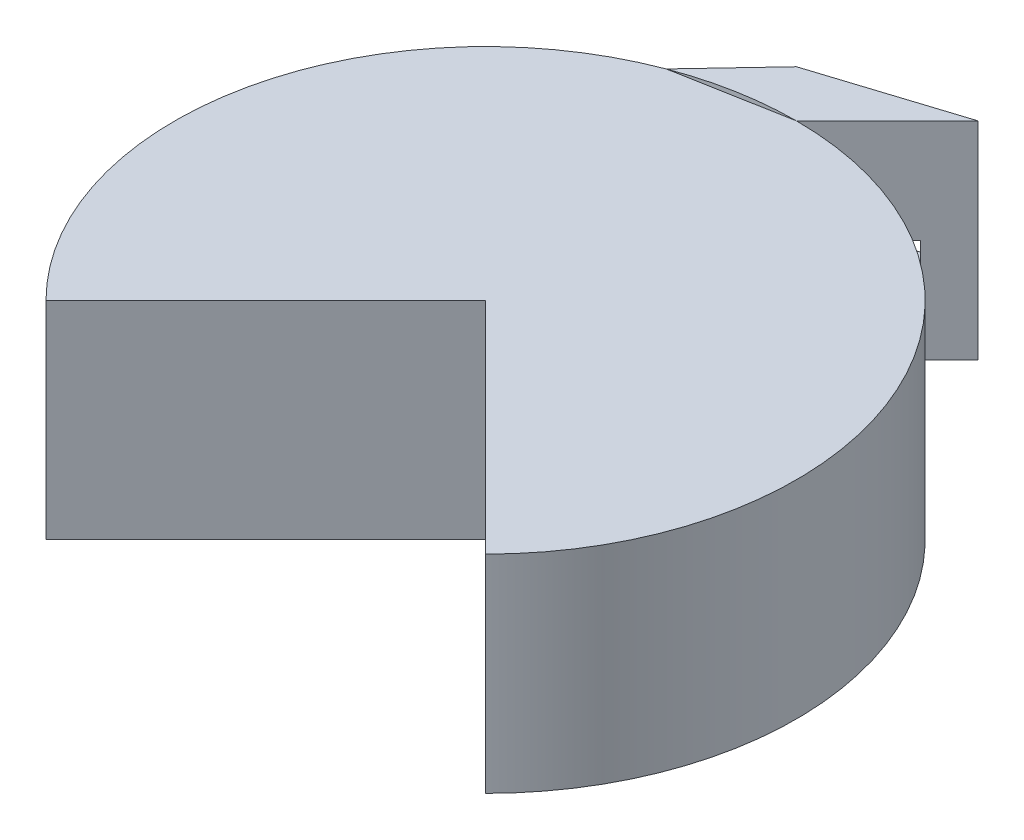
from build123d import *

# Parameters (mm, degrees)
BOSS_EXTRUDE2_DEPTH = 50
CUT_EXTRUDE1_DEPTH  = 16
SKETCH3_R           = 18
CUT_EXTRUDE2_DEPTH  = 30
SKETCH4_R           = 18
CUT_EXTRUDE3_DEPTH  = 30
SKETCH7_R           = 15
CUT_EXTRUDE4_DEPTH  = 30
SKETCH9_R           = 15
CUT_EXTRUDE5_DEPTH  = 30


with BuildPart() as part:
    # Sketch1 → Boss-Extrude2 (new body)
    with BuildSketch(Plane(origin=(0, 0, 0), x_dir=(1, 0, 0), z_dir=(0, 1, 0))):
        with BuildLine():
            Line((0, 75), (0, 0))
            Line((0, 0), (53.033008589, -53.033008589))
            ThreePointArc((53.033008589, -53.033008589), (69.290964938, -28.701257427), (75, 0))
            ThreePointArc((75, 0), (53.033008589, 53.033008589), (0, 75))
        make_face()
        with BuildLine():
            Line((-53.033008589, -53.033008589), (0, 0))
            Line((0, 0), (0, 75))
            Line((0, 75), (-75, 0))
            ThreePointArc((-75, 0), (-69.290964938, -28.701257427), (-53.033008589, -53.033008589))
        make_face()
        with BuildLine():
            Line((-75, 0), (0, 75))
            Line((0, 75), (-26.555455015, 70.141341654))
            ThreePointArc((-26.555455015, 70.141341654), (-61.711664724, 42.622417071), (-75, 0))
        make_face()
        with BuildLine():
            ThreePointArc((-26.555455015, 70.141341654), (-13.498136464, 73.775336746), (0, 75))
            Line((0, 75), (-11.313708499, 86.313708499))
            Line((-11.313708499, 86.313708499), (-26.555455015, 70.141341654))
        make_face()
        Polygon((0, 75), (21.906905273, 96.906905273), (-11.313708499, 86.313708499), align=None)
    extrude(amount=BOSS_EXTRUDE2_DEPTH)

    # Sketch2 → Cut-Extrude1 (cut)
    with BuildSketch(Plane(origin=(-26.027142022, 0, -81.621974096), x_dir=(-0.952734996, 0, 0.303802613), z_dir=(-0.303802613, 0, -0.952734996))):
        Polygon((-32.87770529, 25), (-41.594875837, 25), (-41.594875837, 19), (-21.594875837, 19), (-21.594875837, 25), align=None)
    extrude(amount=-CUT_EXTRUDE1_DEPTH, mode=Mode.SUBTRACT)

    # Sketch3 → Cut-Extrude2 (cut)
    with BuildSketch(Plane.XZ):
        with Locations((-38.637033052, 10.352761804)):
            Circle(SKETCH3_R)
    extrude(amount=-CUT_EXTRUDE2_DEPTH, mode=Mode.SUBTRACT)

    # Sketch4 → Cut-Extrude3 (cut)
    with BuildSketch(Plane(origin=(0, 0, 0), x_dir=(-1, 0, 0), z_dir=(0, -1, 0))):
        with Locations((-38.637033052, -10.352761804)):
            Circle(SKETCH4_R)
    extrude(amount=-CUT_EXTRUDE3_DEPTH, mode=Mode.SUBTRACT)

    # Sketch7 → Cut-Extrude4 (cut)
    with BuildSketch(Plane(origin=(0, 0, 0), x_dir=(-1, 0, 0), z_dir=(0, -1, 0))):
        with Locations((38.637033052, 44.282032303)):
            Circle(SKETCH7_R)
    extrude(amount=-CUT_EXTRUDE4_DEPTH, mode=Mode.SUBTRACT)

    # Sketch9 → Cut-Extrude5 (cut)
    with BuildSketch(Plane.XZ):
        with Locations((38.637033052, -44.282032303)):
            Circle(SKETCH9_R)
    extrude(amount=-CUT_EXTRUDE5_DEPTH, mode=Mode.SUBTRACT)


solid = part.part
